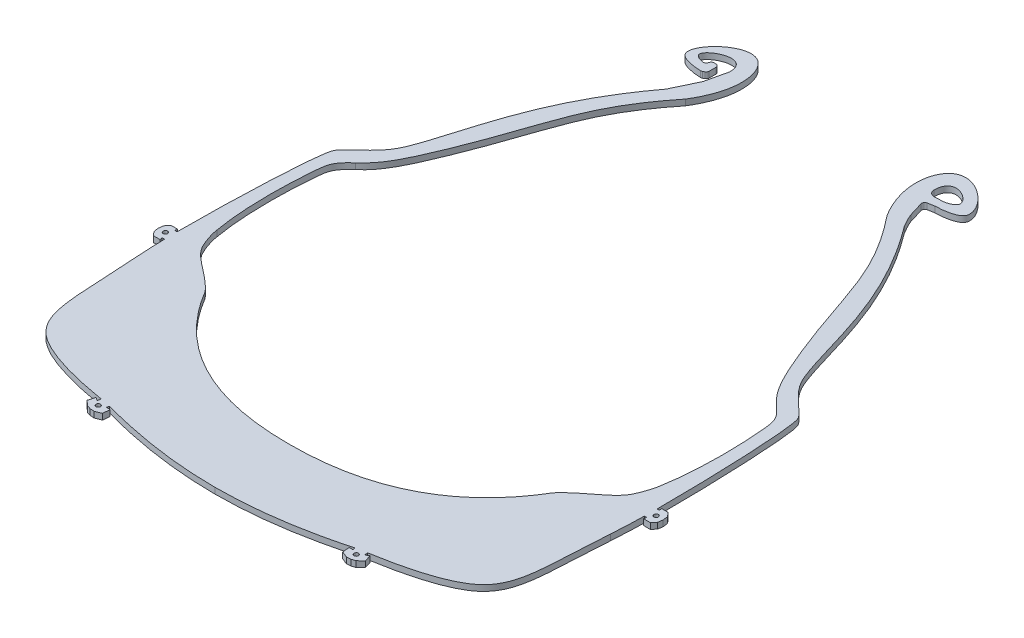
from build123d import *

# Parameters (mm, degrees)
SKETCH2_R           = 0.75
BOSS_EXTRUDE2_DEPTH = 2


with BuildPart() as part:
    # Sketch2 → Boss-Extrude2 (new body)
    with BuildSketch(Plane(origin=(0, 0, 0), x_dir=(1, 0, 0), z_dir=(0, 1, 0))):
        with BuildLine():
            Line((-16.94232243, 4635.297018365), (-18.534662591, 4633.795971308))
            Line((-18.534662591, 4633.795971308), (-19.887255597, 4633.340434244))
            Line((-19.887255597, 4633.340434244), (-21.312460887, 4633.264199495))
            Line((-21.312460887, 4633.264199495), (-23.346608072, 4634.07100473))
            Line((-23.346608072, 4634.07100473), (-23.573607956, 4636.472511323))
            Line((-23.573607956, 4636.472511323), (-22.26922003, 4636.472511323))
            Line((-22.26922003, 4636.472511323), (-22.498511996, 4637.355076027))
            add(Edge.make_bspline(
                [(-63.92338013, 4631.426207785), (-49.997175973, 4631.453371402), (-36.074978393, 4633.559092847), (-22.498511996, 4637.355076027)],
                knots=[0.500293183, 0.500293183, 0.500293183, 0.500293183, 0.981944699, 0.981944699, 0.981944699, 0.981944699], degree=3))
            add(Edge.make_bspline(
                [(-63.92338013, 4631.426207785), (-77.849584288, 4631.453371402), (-91.771781867, 4633.559092847), (-105.348248264, 4637.355076027)],
                knots=[0.500293183, 0.500293183, 0.500293183, 0.500293183, 0.981944699, 0.981944699, 0.981944699, 0.981944699], degree=3))
            Line((-105.348248264, 4637.355076027), (-105.57754023, 4636.472511323))
            Line((-105.57754023, 4636.472511323), (-104.273152305, 4636.472511323))
            Line((-104.273152305, 4636.472511323), (-104.500152189, 4634.07100473))
            Line((-104.500152189, 4634.07100473), (-106.534299374, 4633.264199495))
            Line((-106.534299374, 4633.264199495), (-107.959504664, 4633.340434244))
            Line((-107.959504664, 4633.340434244), (-109.31209767, 4633.795971308))
            Line((-109.31209767, 4633.795971308), (-110.904437831, 4635.297018365))
            Line((-110.904437831, 4635.297018365), (-110.228421491, 4637.612566847))
            Line((-110.228421491, 4637.612566847), (-109.111012106, 4636.936921529))
            Line((-109.111012106, 4636.936921529), (-108.903375625, 4638.035656948))
            add(Edge.make_bspline(
                [(-108.903375625, 4638.035656948), (-118.821969125, 4639.685871765), (-132.493488743, 4643.060373116), (-144.218775593, 4654.394416396), (-143.099113193, 4666.334603474), (-144.46397827, 4684.514714632)],
                knots=[0.018902136, 0.018902136, 0.018902136, 0.018902136, 0.394121885, 0.490994555, 0.987628845, 0.987628845, 0.987628845, 0.987628845], degree=3))
            add(Edge.make_bspline(
                [(-144.46397827, 4684.514714632), (-144.606093665, 4687.588466409), (-144.901928293, 4691.324791696), (-144.93974364, 4695.519138342)],
                knots=[0.004734857, 0.004734857, 0.004734857, 0.004734857, 0.035161677, 0.035161677, 0.035161677, 0.035161677], degree=3))
            Line((-144.93974364, 4695.519138342), (-145.773758332, 4695.519138342))
            Line((-145.773758332, 4695.519138342), (-145.597312449, 4694.624725063))
            Line((-145.597312449, 4694.624725063), (-147.837087324, 4694.624725063))
            Line((-147.837087324, 4694.624725063), (-148.98298998, 4695.944509376))
            Line((-148.98298998, 4695.944509376), (-149.222790895, 4697.597182293))
            Line((-149.222790895, 4697.597182293), (-149.027988208, 4699.255761252))
            Line((-149.027988208, 4699.255761252), (-147.918372484, 4700.606196913))
            Line((-147.918372484, 4700.606196913), (-145.679424713, 4700.667060475))
            Line((-145.679424713, 4700.667060475), (-145.774014845, 4699.790846236))
            Line((-145.774014845, 4699.790846236), (-144.997793977, 4699.790846236))
            add(Edge.make_bspline(
                [(-144.997793977, 4699.790846236), (-145.033758852, 4718.753185432), (-143.793301684, 4748.148684218), (-140.842693737, 4752.209763426), (-133.443044132, 4758.139026966), (-125.725023595, 4776.076706667), (-122.75385973, 4799.368879532), (-104.139698199, 4824.132858298)],
                knots=[0.044450265, 0.044450265, 0.044450265, 0.044450265, 0.175222915, 0.204984692, 0.326836548, 0.407861227, 1, 1, 1, 1], degree=3))
            Line((-104.139698199, 4824.132858298), (-100.134886925, 4832.530370573))
            Line((-100.134886925, 4832.530370573), (-98.443108393, 4839.91280291))
            add(Edge.make_bspline(
                [(-98.443108393, 4839.91280291), (-98.448920719, 4840.617831915), (-99.437775516, 4847.664959355), (-110.959133419, 4841.358583438), (-107.780345645, 4838.705548355), (-106.624271481, 4838.372995162), (-105.90102593, 4838.245393324)],
                knots=[0.039445136, 0.039445136, 0.039445136, 0.039445136, 0.048334816, 0.142928243, 0.155381436, 0.172866754, 0.172866754, 0.172866754, 0.172866754], degree=3))
            ThreePointArc((-105.90102593, 4838.245393324), (-105.232166827, 4838.361355236), (-104.791465543, 4838.87769044))
            Line((-104.791465543, 4838.87769044), (-104.645465971, 4839.26529628))
            ThreePointArc((-104.645465971, 4839.26529628), (-104.278644907, 4839.735145105), (-103.70965166, 4839.91280291))
            Line((-103.70965166, 4839.91280291), (-103.102970113, 4839.91280291))
            ThreePointArc((-103.102970113, 4839.91280291), (-102.395863331, 4839.619909691), (-102.102970113, 4838.91280291))
            Line((-102.102970113, 4838.91280291), (-102.102970113, 4836.630930716))
            ThreePointArc((-102.102970113, 4836.630930716), (-102.237874833, 4836.129323143), (-102.606190428, 4835.763054029))
            Line((-102.606190428, 4835.763054029), (-103.156933754, 4835.447804063))
            ThreePointArc((-103.156933754, 4835.447804063), (-103.403604203, 4835.347463125), (-103.668011051, 4835.315782966))
            add(Edge.make_bspline(
                [(-103.668011051, 4835.315782966), (-106.394251846, 4835.354765686), (-110.958117582, 4836.318232066), (-112.854242874, 4842.52938332), (-95.428175463, 4857.519566026), (-90.931667557, 4835.784474822), (-97.971470578, 4824.478936283)],
                knots=[0.331986167, 0.331986167, 0.331986167, 0.331986167, 0.418389335, 0.461523944, 0.763332252, 1, 1, 1, 1], degree=3))
            add(Edge.make_bspline(
                [(-135.032740768, 4750.111001922), (-130.50511155, 4753.904272028), (-113.081855026, 4791.28530442), (-114.659675591, 4803.651217025), (-97.971470578, 4824.478936283)],
                knots=[0, 0, 0, 0, 0.147117654, 0.925748444, 0.925748444, 0.925748444, 0.925748444], degree=3))
            add(Edge.make_bspline(
                [(-138.776603849, 4707.061813065), (-140.372417965, 4715.665959829), (-140.797792532, 4730.905308146), (-139.055824108, 4746.24867545), (-136.530200286, 4748.70910668), (-135.032740768, 4750.111001922)],
                knots=[0, 0, 0, 0, 0.797699661, 0.897699661, 1, 1, 1, 1], degree=3))
            add(Edge.make_bspline(
                [(-122.553716851, 4686.669702846), (-124.458572981, 4689.514746254), (-133.378914312, 4695.631638467), (-134.862520268, 4697.627016687), (-136.765281392, 4699.957235784), (-138.495666225, 4704.644766972), (-138.776603849, 4707.061813065)],
                knots=[0, 0, 0, 0, 0.517384858, 0.711983816, 0.762677817, 1, 1, 1, 1], degree=3))
            add(Edge.make_bspline(
                [(-63.92338013, 4656.572608608), (-104.524638736, 4656.452117341), (-122.553716851, 4686.669702846)],
                knots=[0, 0, 0, 1, 1, 1], degree=2))
            add(Edge.make_bspline(
                [(-63.92338013, 4656.572608608), (-23.322121525, 4656.452117341), (-5.29304341, 4686.669702846)],
                knots=[0, 0, 0, 1, 1, 1], degree=2))
            add(Edge.make_bspline(
                [(-5.29304341, 4686.669702846), (-3.38818728, 4689.514746254), (5.532154051, 4695.631638467), (7.015760007, 4697.627016687), (8.918521131, 4699.957235784), (10.648905964, 4704.644766972), (10.929843589, 4707.061813065)],
                knots=[0, 0, 0, 0, 0.517384858, 0.711983816, 0.762677817, 1, 1, 1, 1], degree=3))
            add(Edge.make_bspline(
                [(10.929843589, 4707.061813065), (12.525657705, 4715.665959829), (12.951032272, 4730.905308146), (11.209063847, 4746.24867545), (8.683440025, 4748.70910668), (7.185980508, 4750.111001922)],
                knots=[0, 0, 0, 0, 0.797699661, 0.897699661, 1, 1, 1, 1], degree=3))
            add(Edge.make_bspline(
                [(7.185980508, 4750.111001922), (2.658351289, 4753.904272028), (-14.764905235, 4791.28530442), (-13.18708467, 4803.651217025), (-29.875289683, 4824.478936283)],
                knots=[0, 0, 0, 0, 0.147117654, 0.925748444, 0.925748444, 0.925748444, 0.925748444], degree=3))
            add(Edge.make_bspline(
                [(-24.45590975, 4835.313908206), (-21.671132761, 4835.311498884), (-16.909265089, 4836.272618376), (-14.972315663, 4842.521508455), (-32.422600191, 4857.519670275), (-36.915092703, 4835.784474822), (-29.875289683, 4824.478936283)],
                knots=[0.329045507, 0.329045507, 0.329045507, 0.329045507, 0.418095269, 0.461523944, 0.763332252, 1, 1, 1, 1], degree=3))
            Line((-24.45590975, 4835.313908206), (-26.764747559, 4834.907599954))
            ThreePointArc((-26.764747559, 4834.907599954), (-27.443301913, 4834.446485933), (-27.548494359, 4833.632854135))
            Line((-27.548494359, 4833.632854135), (-26.0413483, 4828.656878353))
            add(Edge.make_bspline(
                [(-23.707062062, 4824.132858298), (-24.602825604, 4825.752639792), (-25.236969166, 4826.64616849), (-26.0413483, 4828.656878353)],
                knots=[0, 0, 0, 0, 0.008448935, 0.008448935, 0.008448935, 0.008448935], degree=3))
            add(Edge.make_bspline(
                [(17.151033717, 4699.790846236), (17.186998591, 4718.753185432), (15.946541424, 4748.148684218), (12.995933477, 4752.209763426), (5.596283872, 4758.139026966), (-2.121736665, 4776.076706667), (-5.092900531, 4799.368879532), (-23.707062062, 4824.132858298)],
                knots=[0.044450265, 0.044450265, 0.044450265, 0.044450265, 0.175222915, 0.204984692, 0.326836548, 0.407861227, 1, 1, 1, 1], degree=3))
            Line((17.151033717, 4699.790846236), (17.927254585, 4699.790846236))
            Line((17.927254585, 4699.790846236), (17.832664452, 4700.667060475))
            Line((17.832664452, 4700.667060475), (20.071612224, 4700.606196913))
            Line((20.071612224, 4700.606196913), (21.181227948, 4699.255761252))
            Line((21.181227948, 4699.255761252), (21.376030634, 4697.597182293))
            Line((21.376030634, 4697.597182293), (21.136229719, 4695.944509376))
            Line((21.136229719, 4695.944509376), (19.990327064, 4694.624725063))
            Line((19.990327064, 4694.624725063), (17.750552188, 4694.624725063))
            Line((17.750552188, 4694.624725063), (17.926998071, 4695.519138342))
            Line((17.926998071, 4695.519138342), (17.092983379, 4695.519138342))
            add(Edge.make_bspline(
                [(16.61721801, 4684.514714632), (16.759333405, 4687.588466409), (17.055168032, 4691.324791696), (17.092983379, 4695.519138342)],
                knots=[0.004734857, 0.004734857, 0.004734857, 0.004734857, 0.035161677, 0.035161677, 0.035161677, 0.035161677], degree=3))
            add(Edge.make_bspline(
                [(-18.943384636, 4638.035656948), (-9.024791136, 4639.685871765), (4.646728482, 4643.060373116), (16.372015333, 4654.394416396), (15.252352932, 4666.334603474), (16.61721801, 4684.514714632)],
                knots=[0.018902136, 0.018902136, 0.018902136, 0.018902136, 0.394121885, 0.490994555, 0.987628845, 0.987628845, 0.987628845, 0.987628845], degree=3))
            Line((-18.943384636, 4638.035656948), (-18.735748154, 4636.936921529))
            Line((-18.735748154, 4636.936921529), (-17.61833877, 4637.612566847))
            Line((-17.61833877, 4637.612566847), (-16.94232243, 4635.297018365))
        make_face()
        with Locations((-20.331640643, 4635.661753265)):
            Circle(SKETCH2_R, mode=Mode.SUBTRACT)
        with Locations((18.97346222, 4697.629831976)):
            Circle(SKETCH2_R, mode=Mode.SUBTRACT)
        with Locations((-146.82022248, 4697.629831976)):
            Circle(SKETCH2_R, mode=Mode.SUBTRACT)
        with Locations((-107.515119617, 4635.661753265)):
            Circle(SKETCH2_R, mode=Mode.SUBTRACT)
        with BuildLine():
            Line((-26.621350229, 4837.935486282), (-27.296358217, 4837.899198988))
            ThreePointArc((-27.296358217, 4837.899198988), (-28.785423811, 4838.450322851), (-29.403651867, 4839.91280291))
            add(Edge.make_bspline(
                [(-29.403651867, 4839.91280291), (-29.397839541, 4840.617831915), (-28.338396622, 4847.667580663), (-18.260003508, 4841.087411447), (-23.548740991, 4837.831323077), (-24.826688271, 4838.031964289), (-26.621350229, 4837.935486282)],
                knots=[0.039445136, 0.039445136, 0.039445136, 0.039445136, 0.048334816, 0.142928243, 0.159172541, 0.210777803, 0.210777803, 0.210777803, 0.210777803], degree=3))
        make_face(mode=Mode.SUBTRACT)
    extrude(amount=BOSS_EXTRUDE2_DEPTH)


solid = part.part
